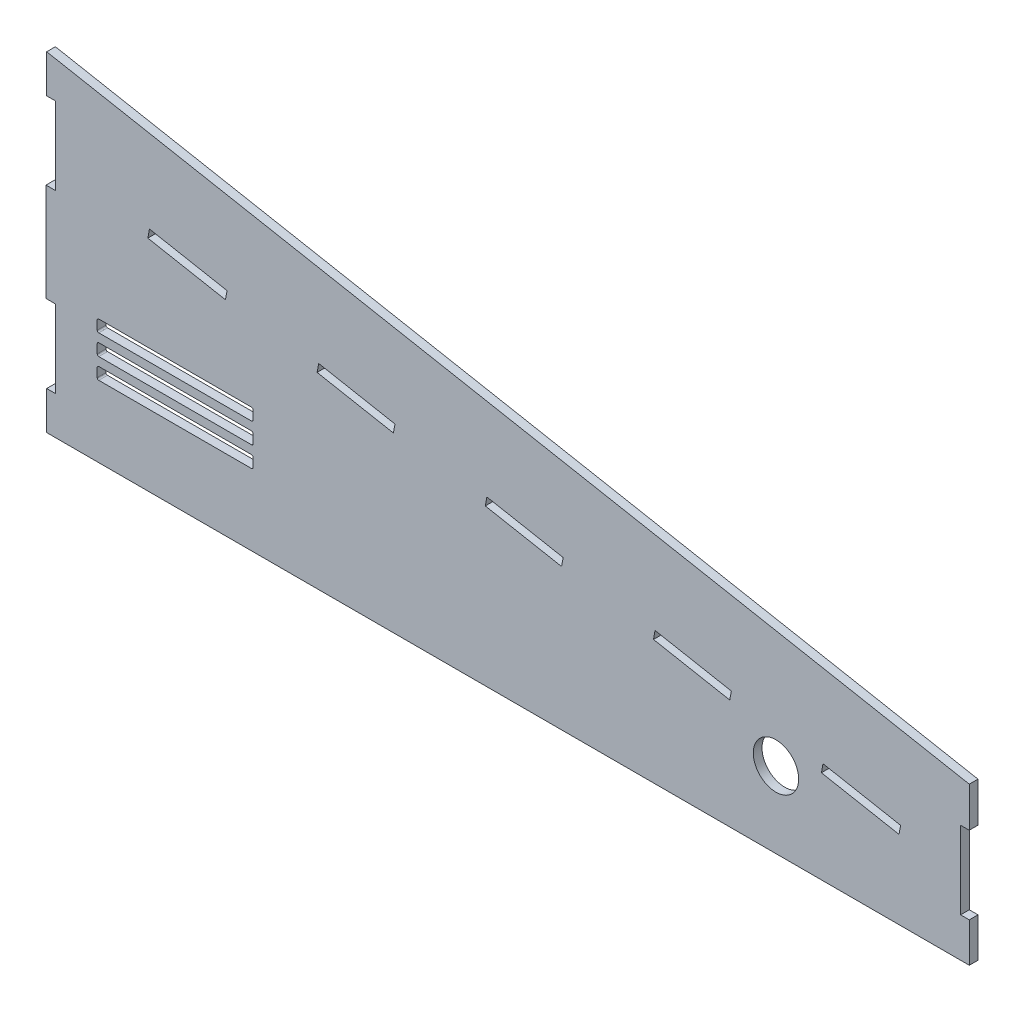
from build123d import *

# Parameters (mm, degrees)
BOSS_EXTRUDE1_DEPTH = 5.7
SKETCH2_R           = 14.85
CUT_EXTRUDE1_DEPTH  = 6.7


with BuildPart() as part:
    # Sketch1 → Boss-Extrude1 (new body)
    with BuildSketch(Plane.XY):
        Polygon((-159.83650641, 166.052929421), (-154.13650641, 166.052929421), (-154.13650641, 115.252929421), (-160.286019508, 115.252929421), (-160.286019508, 50.952929421), (-154.13650641, 50.952929421), (-154.13650641, 0.152929421), (-159.83650641, 0.152929421), (-159.83650641, -24.847070579), (444.06349359, -24.847070579), (444.06349359, 0.899402865), (438.36349359, 0.899402865), (438.36349359, 51.699402865), (444.06349359, 51.699402865), (444.06349359, 77.821679421), (-159.83650641, 191.052929421), align=None)
    extrude(amount=BOSS_EXTRUDE1_DEPTH)

    # Sketch2 → Cut-Extrude1 (cut, through all)
    with BuildSketch(Plane.XY.offset(5.7)):
        with Locations((317.523696403, 24.846574105)):
            Circle(SKETCH2_R)
        Polygon((287.261228118, 47.129406511), (288.311706475, 52.731771656), (238.381855706, 62.093929643), (237.331377349, 56.491564498), align=None)
        Polygon((177.179115935, 67.770488147), (178.229594292, 73.372853292), (128.299743522, 82.735011279), (127.249265166, 77.132646134), align=None)
        Polygon((-92.56491366, 124.199043845), (-41.76491366, 114.673727458), (-42.83369916, 108.973727458), (-93.63369916, 118.499043845), align=None)
        Polygon((18.217631339, 103.376092915), (68.147482108, 94.013934928), (67.097003751, 88.411569783), (17.167152982, 97.77372777), align=None)
        with BuildLine():
            Line((-24.756085794, 42.151529897), (-24.756085794, 36.301350189))
            ThreePointArc((-24.756085794, 36.301350189), (-25.048979012, 35.594243408), (-25.756085794, 35.301350189))
            Line((-25.756085794, 35.301350189), (-125.756085794, 35.301350189))
            ThreePointArc((-125.756085794, 35.301350189), (-126.463192575, 35.594243408), (-126.756085794, 36.301350189))
            Line((-126.756085794, 36.301350189), (-126.756085794, 42.151529897))
            ThreePointArc((-126.756085794, 42.151529897), (-126.463192575, 42.858636678), (-125.756085794, 43.151529897))
            Line((-125.756085794, 43.151529897), (-25.756085794, 43.151529897))
            ThreePointArc((-25.756085794, 43.151529897), (-25.048979012, 42.858636678), (-24.756085794, 42.151529897))
        make_face()
        Polygon((348.312558617, 41.531771968), (347.252926688, 35.880589395), (398.052926688, 26.355273008), (399.112558617, 32.006455581), align=None)
        with BuildLine():
            Line((-25.756085794, 56.60407475), (-125.756085794, 56.60407475))
            ThreePointArc((-125.756085794, 56.60407475), (-126.463192575, 56.311181531), (-126.756085794, 55.60407475))
            Line((-126.756085794, 55.60407475), (-126.756085794, 49.753895042))
            ThreePointArc((-126.756085794, 49.753895042), (-126.463192575, 49.046788261), (-125.756085794, 48.753895042))
            Line((-125.756085794, 48.753895042), (-25.756085794, 48.753895042))
            ThreePointArc((-25.756085794, 48.753895042), (-25.048979012, 49.046788261), (-24.756085794, 49.753895042))
            Line((-24.756085794, 49.753895042), (-24.756085794, 55.60407475))
            ThreePointArc((-24.756085794, 55.60407475), (-25.048979012, 56.311181531), (-25.756085794, 56.60407475))
        make_face()
        with BuildLine():
            Line((-25.756085794, 29.698985049), (-125.756085794, 29.698985049))
            ThreePointArc((-125.756085794, 29.698985049), (-126.463192575, 29.40609183), (-126.756085794, 28.698985049))
            Line((-126.756085794, 28.698985049), (-126.756085794, 22.848805341))
            ThreePointArc((-126.756085794, 22.848805341), (-126.463192575, 22.14169856), (-125.756085794, 21.848805341))
            Line((-125.756085794, 21.848805341), (-25.756085794, 21.848805341))
            ThreePointArc((-25.756085794, 21.848805341), (-25.048979012, 22.14169856), (-24.756085794, 22.848805341))
            Line((-24.756085794, 22.848805341), (-24.756085794, 28.698985049))
            ThreePointArc((-24.756085794, 28.698985049), (-25.048979012, 29.40609183), (-25.756085794, 29.698985049))
        make_face()
    extrude(amount=-CUT_EXTRUDE1_DEPTH, mode=Mode.SUBTRACT)


solid = part.part
